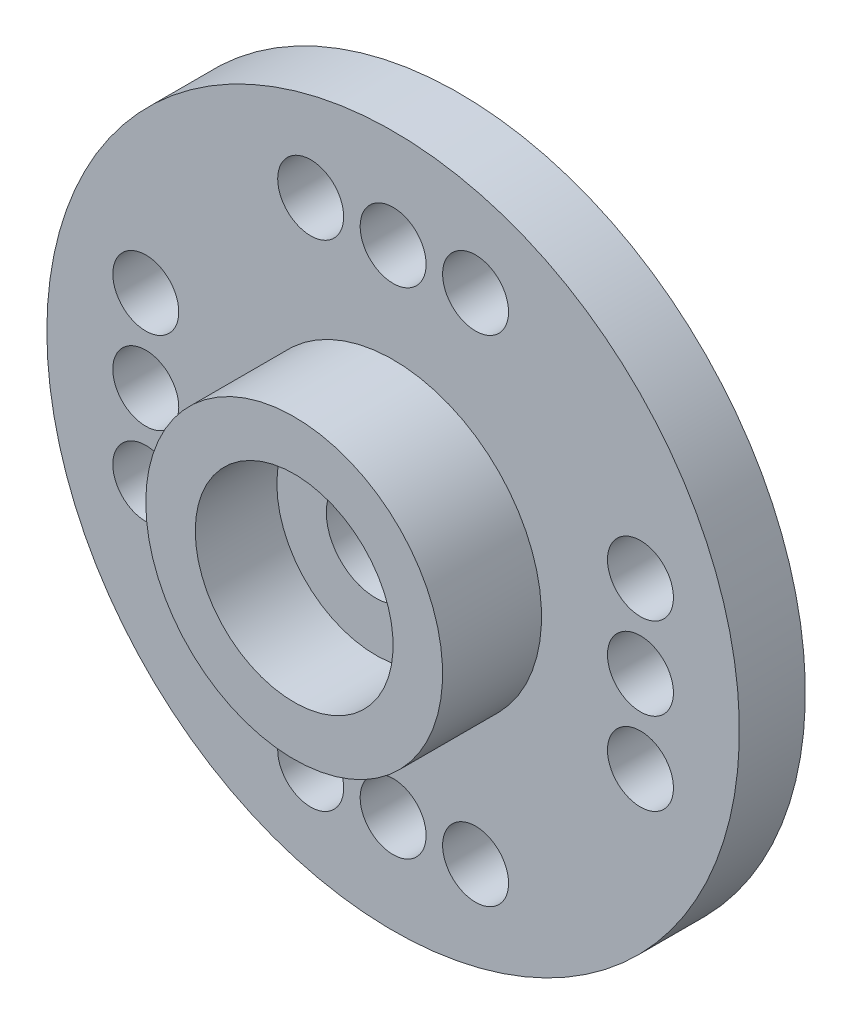
from build123d import *

# Parameters (mm, degrees)
CROQUIS3_R            = 1
CORTAR_EXTRUIR1_DEPTH = 3


with BuildPart() as part:
    # Croquis2 → Revolución1 (revolve)
    with BuildSketch(Plane(origin=(0, 0, 0), x_dir=(0, 0, -1), z_dir=(1, 0, 0))):
        Polygon((0, 1.5), (0, 3), (1.5, 3), (1.5, 3.5), (-0.5, 3.5), (-0.5, 4.5), (1, 4.5), (1, 10.5), (-1, 10.5), (-1, 4.5), (-4, 4.5), (-4, 3), (-1.525538697, 3), (-1.525538697, 1.5), align=None)
    revolve(axis=Axis((0, 0, 0), (0, 0, 1)))

    # Croquis3 → Cortar-Extruir1 (cut)
    with BuildSketch(Plane(origin=(0, 0, -1), x_dir=(-1, 0, 0), z_dir=(0, 0, -1))):
        with Locations((7.5, 2.5)):
            Circle(CROQUIS3_R)
        with Locations((0, 7.5)):
            Circle(CROQUIS3_R)
        with Locations((7.5, 0)):
            Circle(CROQUIS3_R)
        with Locations((-7.5, 0)):
            Circle(CROQUIS3_R)
        with Locations((0, -7.5)):
            Circle(CROQUIS3_R)
        with Locations((2.5, -7.5)):
            Circle(CROQUIS3_R)
        with Locations((-7.5, -2.5)):
            Circle(CROQUIS3_R)
        with Locations((-2.5, 7.5)):
            Circle(CROQUIS3_R)
        with Locations((7.5, -2.5)):
            Circle(CROQUIS3_R)
        with Locations((-2.5, -7.5)):
            Circle(CROQUIS3_R)
        with Locations((-7.5, 2.5)):
            Circle(CROQUIS3_R)
        with Locations((2.5, 7.5)):
            Circle(CROQUIS3_R)
    extrude(amount=-CORTAR_EXTRUIR1_DEPTH, mode=Mode.SUBTRACT)


solid = part.part
